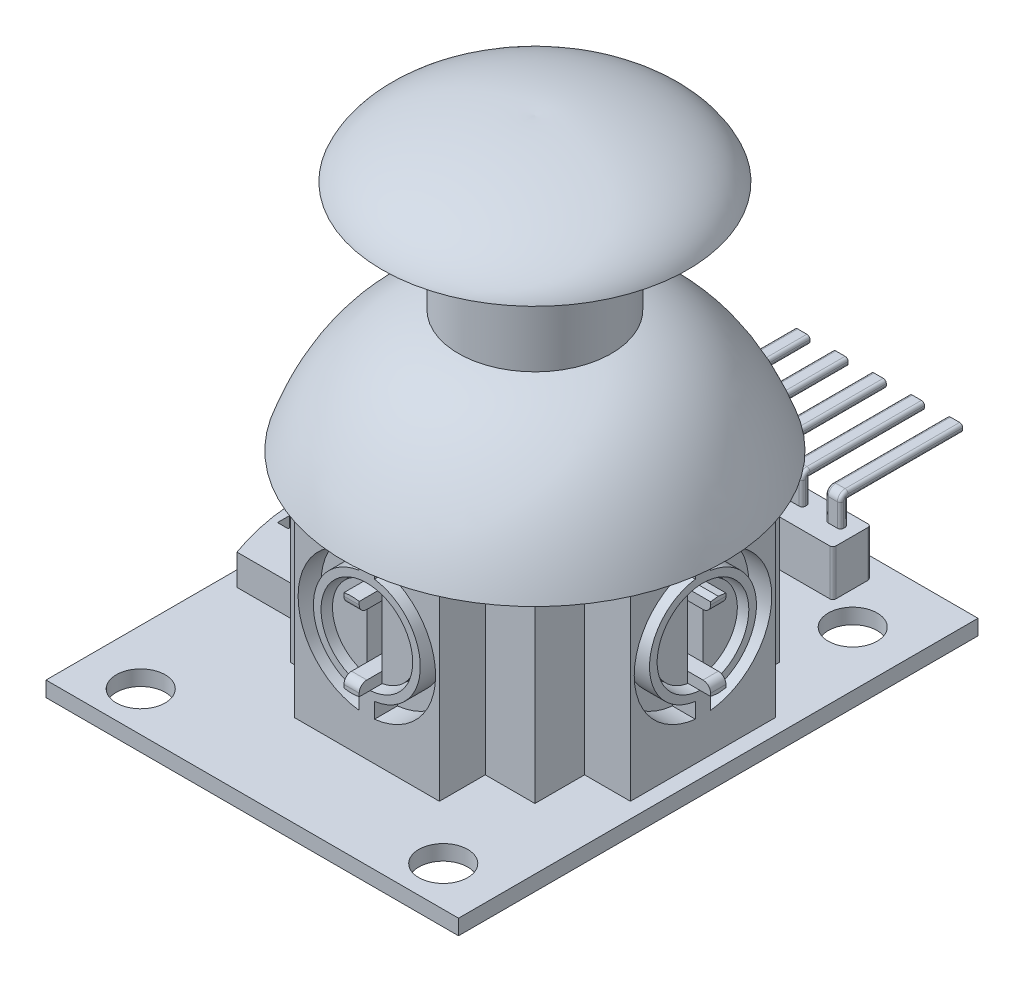
from build123d import *

# Parameters (mm, degrees)
IZIM1_W                           = 27
IZIM1_H                           = 34
IZIM1_R                           = 1.6
Y_KSEKLIK_EKSTR_ZYON1_DEPTH       = 1
IZIM2_W                           = 16
IZIM2_H                           = 16
IZIM2_W_2                         = 15.6
IZIM2_H_2                         = 15.6
Y_KSEKLIK_EKSTR_ZYON2_DEPTH       = 12
IZIM3_W                           = 9.5
IZIM3_H                           = 12
Y_KSEKLIK_EKSTR_ZYON3_DEPTH       = 3
IZIM4_R                           = 3
KES_EKSTR_ZYON1_DEPTH             = 1.5
IZIM5_R                           = 2.75
Y_KSEKLIK_EKSTR_ZYON4_DEPTH       = 1
Y_KSEKLIK_EKSTR_ZYON5_DEPTH       = 1.5
RADYUS1_R                         = 0.5
IZIM7_W                           = 1
IZIM7_H                           = 4
KES_EKSTR_ZYON2_DEPTH             = 1.5
IZIM8_W                           = 0.7
IZIM8_H                           = 5
Y_KSEKLIK_EKSTR_ZYON6_DEPTH       = 2
IZIM9_W                           = 5.85
IZIM9_H                           = 4.793448
Y_KSEKLIK_EKSTR_ZYON7_DEPTH       = 1
IZIM10_W                          = 5.65
IZIM10_H                          = 4.793448
Y_KSEKLIK_EKSTR_ZYON8_DEPTH       = 0.2
IZIM11_R                          = 0.15
Y_KSEKLIK_EKSTR_ZYON9_DEPTH       = 0.1
IZIM12_R                          = 1.75
Y_KSEKLIK_EKSTR_ZYON10_DEPTH      = 2
KES_EKSTR_ZYON3_DEPTH             = 2
IZIM14_R                          = 1.5
Y_KSEKLIK_EKSTR_ZYON11_DEPTH      = 31
IZIM15_R                          = 1.4
Y_KSEKLIK_EKSTR_ZYON12_DEPTH      = 8
IZIM17_R                          = 2.15
Y_KSEKLIK_EKSTR_ZYON14_DEPTH      = 2
Y_KSEKLIK_EKSTR_ZYON15_DEPTH      = 1
IZIM22_W                          = 9.5
IZIM22_H                          = 12
Y_KSEKLIK_EKSTR_ZYON16_DEPTH      = 3
KES_EKSTR_ZYON4_DEPTH             = 1.5
IZIM24_R                          = 3
KES_EKSTR_ZYON5_DEPTH             = 1.5
IZIM25_R                          = 2.75
Y_KSEKLIK_EKSTR_ZYON17_DEPTH      = 1
Y_KSEKLIK_EKSTR_ZYON18_DEPTH      = 1.5
RADYUS2_R                         = 0.5
IZIM27_W                          = 1
IZIM27_H                          = 4
KES_EKSTR_ZYON6_DEPTH             = 1.5
Y_KSEKLIK_EKSTR_ZYON19_DEPTH      = 1
Y_KSEKLIK_EKSTR_ZYON20_DEPTH      = 3
Y_KSEKLIK_EKSTR_ZYON21_DEPTH      = 0.5
Y_KSEKLIK_EKSTR_ZYON21_DEPTH_BACK = 0.5
Y_KSEKLIK_EKSTR_ZYON22_DEPTH      = 0.5
Y_KSEKLIK_EKSTR_ZYON22_DEPTH_BACK = 0.5
Y_KSEKLIK_EKSTR_ZYON23_DEPTH      = 0.5
Y_KSEKLIK_EKSTR_ZYON23_DEPTH_BACK = 0.5
Y_KSEKLIK_EKSTR_ZYON24_DEPTH      = 0.5
Y_KSEKLIK_EKSTR_ZYON24_DEPTH_BACK = 0.5
Y_KSEKLIK_EKSTR_ZYON25_DEPTH      = 0.5
Y_KSEKLIK_EKSTR_ZYON25_DEPTH_BACK = 0.5
RADYUS3_R                         = 0.2


with BuildPart() as part:
    # Çizim1 → Yükseklik-Ekstrüzyon1 (new body)
    with BuildSketch(Plane(origin=(0, 0, 0), x_dir=(1, 0, 0), z_dir=(0, 1, 0))):
        Rectangle(IZIM1_W, IZIM1_H)
        with Locations(Location((-9.9, -14.4, 0), (0, 0, 270))):
            Circle(IZIM1_R, mode=Mode.SUBTRACT)
        with Locations(Location((9.9, -14.4, 0), (0, 0, 90))):
            Circle(IZIM1_R, mode=Mode.SUBTRACT)
        with Locations(Location((-9.9, 12.4, 0), (0, 0, 270))):
            Circle(IZIM1_R, mode=Mode.SUBTRACT)
        with Locations(Location((9.9, 12.4, 0), (0, 0, 90))):
            Circle(IZIM1_R, mode=Mode.SUBTRACT)
    extrude(amount=Y_KSEKLIK_EKSTR_ZYON1_DEPTH)

    # Çizim2 → Yükseklik-Ekstrüzyon2 (add)
    with BuildSketch(Plane(origin=(0, 1, 0), x_dir=(1, 0, 0), z_dir=(0, 1, 0))):
        with Locations((1.5, 0)):
            Rectangle(IZIM2_W, IZIM2_H)
        with Locations((1.5, 0)):
            Rectangle(IZIM2_W_2, IZIM2_H_2, mode=Mode.SUBTRACT)
    extrude(amount=Y_KSEKLIK_EKSTR_ZYON2_DEPTH)

    # Çizim3 → Yükseklik-Ekstrüzyon3 (add)
    with BuildSketch(Plane.XY.offset(8)):
        with Locations((1.5, 7)):
            Rectangle(IZIM3_W, IZIM3_H)
    extrude(amount=Y_KSEKLIK_EKSTR_ZYON3_DEPTH)

    # Çizim4 → Kes-Ekstrüzyon1 (cut)
    with BuildSketch(Plane.XY.offset(11)):
        with Locations((1.5, 8)):
            Circle(IZIM4_R)
        with BuildLine():
            Line((1, 12.472136), (1, 11.464102))
            ThreePointArc((1, 11.464102), (-2, 8), (1, 4.535898))
            Line((1, 4.535898), (1, 3.527864))
            ThreePointArc((1, 3.527864), (-3, 8), (1, 12.472136))
        make_face()
        with BuildLine():
            Line((2, 12.472136), (2, 11.464102))
            ThreePointArc((2, 11.464102), (5, 8), (2, 4.535898))
            Line((2, 4.535898), (2, 3.527864))
            ThreePointArc((2, 3.527864), (6, 8), (2, 12.472136))
        make_face()
    extrude(amount=-KES_EKSTR_ZYON1_DEPTH, mode=Mode.SUBTRACT)

    # Çizim5 → Yükseklik-Ekstrüzyon4 (add)
    with BuildSketch(Plane.XY.offset(9.5)):
        with Locations((1.5, 8)):
            Circle(IZIM5_R)
    extrude(amount=Y_KSEKLIK_EKSTR_ZYON4_DEPTH)

    # Çizim6 → Yükseklik-Ekstrüzyon5 (add)
    with BuildSketch(Plane.XY.offset(10.5)):
        with BuildLine():
            Line((2, 10.704163), (2, 10))
            Line((2, 10), (1, 10))
            Line((1, 10), (1, 10.704163))
            ThreePointArc((1, 10.704163), (1.5, 10.75), (2, 10.704163))
        make_face()
        with BuildLine():
            Line((1, 6), (2, 6))
            Line((2, 6), (2, 5.295837))
            ThreePointArc((2, 5.295837), (1.5, 5.25), (1, 5.295837))
            Line((1, 5.295837), (1, 6))
        make_face()
    extrude(amount=Y_KSEKLIK_EKSTR_ZYON5_DEPTH)

    # Radyus1
    radyus1_edges = [part.edges().sort_by_distance(p)[0] for p in [
        (1.5, 10, 12),
        (1.5, 6, 12),
    ]]
    fillet(radyus1_edges, radius=RADYUS1_R)

    # Çizim7 → Kes-Ekstrüzyon2 (cut)
    with BuildSketch(Plane.XY.offset(10.5)):
        with Locations((1.5, 8)):
            Rectangle(IZIM7_W, IZIM7_H)
    extrude(amount=-KES_EKSTR_ZYON2_DEPTH, mode=Mode.SUBTRACT)

    # Çizim8 → Yükseklik-Ekstrüzyon6 (add)
    with BuildSketch(Plane(origin=(0, 1, 0), x_dir=(1, 0, 0), z_dir=(0, 1, 0))):
        with BuildLine():
            Line((-12.5, 5.5), (-6.5, 5.5))
            Line((-6.5, 5.5), (-6.5, -5.5))
            Line((-6.5, -5.5), (-12.5, -5.5))
            add(Edge.make_bspline(
                [(-12.5, 5.5), (-14.5, 0), (-12.5, -5.5)],
                knots=[0, 0, 0, 1, 1, 1], degree=2))
        make_face()
        with Locations((-12.5, 0)):
            Rectangle(IZIM8_W, IZIM8_H, mode=Mode.SUBTRACT)
    extrude(amount=Y_KSEKLIK_EKSTR_ZYON6_DEPTH)

    # Çizim9 → Yükseklik-Ekstrüzyon7 (add)
    with BuildSketch(Plane(origin=(0, 3, 0), x_dir=(1, 0, 0), z_dir=(0, 1, 0))):
        with Locations((-9.225, 0)):
            Rectangle(IZIM9_W, IZIM9_H)
    extrude(amount=Y_KSEKLIK_EKSTR_ZYON7_DEPTH)

    # Çizim10 → Yükseklik-Ekstrüzyon8 (add)
    with BuildSketch(Plane(origin=(0, 4, 0), x_dir=(1, 0, 0), z_dir=(0, 1, 0))):
        with Locations((-9.325, 0)):
            Rectangle(IZIM10_W, IZIM10_H)
    extrude(amount=Y_KSEKLIK_EKSTR_ZYON8_DEPTH)

    # Çizim11 → Yükseklik-Ekstrüzyon9 (add)
    with BuildSketch(Plane(origin=(0, 4.2, 0), x_dir=(1, 0, 0), z_dir=(0, 1, 0))):
        with Locations(Location((-11.796392, 2.096724, 0), (0, 0, 270))):
            Circle(IZIM11_R)
        with Locations(Location((-6.853608, 2.096724, 0), (0, 0, 90))):
            Circle(IZIM11_R)
        with Locations(Location((-6.853608, -2.096724, 0), (0, 0, 270))):
            Circle(IZIM11_R)
        with Locations(Location((-11.796392, -2.096724, 0), (0, 0, 90))):
            Circle(IZIM11_R)
    extrude(amount=Y_KSEKLIK_EKSTR_ZYON9_DEPTH)

    # Çizim12 → Yükseklik-Ekstrüzyon10 (add)
    with BuildSketch(Plane(origin=(0, 4.2, 0), x_dir=(1, 0, 0), z_dir=(0, 1, 0))):
        with Locations(Location((-9.325, 0, 0), (0, 0, 270))):
            Circle(IZIM12_R)
    extrude(amount=Y_KSEKLIK_EKSTR_ZYON10_DEPTH)

    # Çizim13 → Kes-Ekstrüzyon3 (cut)
    with BuildSketch(Plane.ZY.offset(6.5)):
        with BuildLine():
            Line((-3.5, 6.2), (-1.926136, 6.2))
            ThreePointArc((-1.926136, 6.2), (0, 11.5), (1.926136, 6.2))
            Line((1.926136, 6.2), (3.5, 6.2))
            ThreePointArc((3.5, 6.2), (3.853553, 6.053553), (4, 5.7))
            Line((4, 5.7), (4, 1))
            Line((4, 1), (-4, 1))
            Line((-4, 1), (-4, 5.7))
            ThreePointArc((-4, 5.7), (-3.853553, 6.053553), (-3.5, 6.2))
        make_face()
    extrude(amount=-KES_EKSTR_ZYON3_DEPTH, mode=Mode.SUBTRACT)

    # Çizim14 → Yükseklik-Ekstrüzyon11 (add)
    with BuildSketch(Plane(origin=(0, 1, 0), x_dir=(1, 0, 0), z_dir=(0, 1, 0))):
        with Locations(Location((1.5, 0, 0), (0, 0, 270))):
            Circle(IZIM14_R)
    extrude(amount=Y_KSEKLIK_EKSTR_ZYON11_DEPTH)

    # Çizim15 → Yükseklik-Ekstrüzyon12 (add)
    with BuildSketch(Plane(origin=(1.5, 0, 0), x_dir=(0, 0, -1), z_dir=(1, 0, 0))):
        with Locations((0, 8.5)):
            Circle(IZIM15_R)
    extrude(amount=-Y_KSEKLIK_EKSTR_ZYON12_DEPTH)

    # Çizim17 → Yükseklik-Ekstrüzyon14 (add)
    with BuildSketch(Plane.ZY.offset(6.5)):
        with Locations((0, 8.5)):
            Circle(IZIM17_R)
    extrude(amount=Y_KSEKLIK_EKSTR_ZYON14_DEPTH)

    # Çizim18 → Yükseklik-Ekstrüzyon15 (add)
    with BuildSketch(Plane.ZY.offset(8.5)):
        with BuildLine():
            Line((1, 8.5), (1, 10.6))
            ThreePointArc((1, 10.6), (0.941421, 10.741421), (0.8, 10.8))
            Line((0.8, 10.8), (-0.8, 10.8))
            ThreePointArc((-0.8, 10.8), (-0.941421, 10.741421), (-1, 10.6))
            Line((-1, 10.6), (-1, 8.5))
            ThreePointArc((-1, 8.5), (0, 7.5), (1, 8.5))
        make_face()
    extrude(amount=Y_KSEKLIK_EKSTR_ZYON15_DEPTH)



with BuildPart() as body_2:
    # Çizim19 → Döndür1 (revolve)
    with BuildSketch(Plane(origin=(1.5, 0, 0), x_dir=(0, 0, -1), z_dir=(1, 0, 0)), mode=Mode.PRIVATE) as d_nd_r1_sk:
        with BuildLine():
            Line((-12.5, 13), (-12.288133, 13))
            add(Edge.make_bspline(
                [(-12.288133, 13), (-12.111507, 13.502279), (-11.702122, 14.536697), (-11.015704, 15.891074), (-10.226286, 17.116712), (-9.058841, 18.530653), (-7.713634, 19.626363), (-6.197298, 20.40463), (-5.366566, 20.692463), (-4.947265, 20.807078)],
                knots=[0.004762, 0.004762, 0.004762, 0.004762, 0.113958, 0.227916, 0.341874, 0.455832, 0.683748, 0.797706, 0.911664, 0.911664, 0.911664, 0.911664], degree=3))
            Line((-4.947265, 20.807078), (-4.8, 20.807078))
            Line((-4.8, 20.807078), (-4.8, 21))
            Line((-4.8, 21), (-4.8, 28.250085))
            Line((-4.8, 28.250085), (-5, 28.250085))
            Line((-5, 28.250085), (-5, 21))
            add(Edge.make_bspline(
                [(-12.5, 13), (-10.213592, 19.574874), (-5, 21)],
                knots=[0, 0, 0, 0.911664, 0.911664, 0.911664], degree=2))
        make_face()
    revolve(d_nd_r1_sk.sketch.rotate(Axis((1.5, 13, 0), (0, 1, 0)), 180), axis=Axis((1.5, 13, 0), (0, 1, 0)))


with BuildPart() as part_1:
    add(part.part)

    add(body_2.part)  # Döndür3 merges body 2
    # Çizim21 → Döndür3 (revolve)
    with BuildSketch(Plane(origin=(1.5, 0, 0), x_dir=(0, 0, -1), z_dir=(1, 0, 0)), mode=Mode.PRIVATE) as d_nd_r3_sk:
        with BuildLine():
            Line((0, 32), (0, 31.800503))
            Line((0, 31.800503), (-0.014182, 31.800503))
            add(Edge.make_bspline(
                [(-0.014182, 31.800503), (-0.21638, 31.814878), (-0.610932, 31.829554), (-1.487447, 31.813408), (-2.658294, 31.705464), (-4.127855, 31.444872), (-5.581424, 31.059598), (-6.945351, 30.557646), (-8.144428, 29.947028), (-8.941287, 29.360532), (-9.424448, 28.847791), (-9.603184, 28.590125), (-9.682203, 28.450085)],
                knots=[0, 0, 0, 0, 0.047842, 0.095684, 0.191367, 0.287051, 0.382735, 0.478418, 0.574102, 0.669786, 0.717628, 0.765469, 0.765469, 0.765469, 0.765469], degree=3))
            Line((-9.682203, 28.450085), (-4.40609, 28.450085))
            Line((-4.40609, 28.450085), (-4.40609, 28.250085))
            Line((-4.40609, 28.250085), (-10, 28.250085))
            add(Edge.make_bspline(
                [(0, 32), (-0.745802, 32.053019), (-4.590452, 31.898517), (-9.220348, 30.199043), (-10, 28.250085)],
                knots=[0, 0, 0, 0, 0.179556, 0.797541, 0.797541, 0.797541, 0.797541], degree=3))
        make_face()
    revolve(d_nd_r3_sk.sketch.rotate(Axis((1.5, 28.250085, 0), (0, 1, 0)), 180), axis=Axis((1.5, 28.250085, 0), (0, 1, 0)))

    # Çizim22 → Yükseklik-Ekstrüzyon16 (add)
    with BuildSketch(Plane(origin=(9.5, 0, 0), x_dir=(0, 0, -1), z_dir=(1, 0, 0))):
        with Locations((0, 7)):
            Rectangle(IZIM22_W, IZIM22_H)
    extrude(amount=Y_KSEKLIK_EKSTR_ZYON16_DEPTH)

    # Çizim23 → Kes-Ekstrüzyon4 (cut)
    with BuildSketch(Plane(origin=(12.5, 0, 0), x_dir=(0, 0, -1), z_dir=(1, 0, 0))):
        with BuildLine():
            Line((-0.5, 12.472136), (-0.5, 11.464102))
            ThreePointArc((-0.5, 11.464102), (-3.5, 8), (-0.5, 4.535898))
            Line((-0.5, 4.535898), (-0.5, 3.527864))
            ThreePointArc((-0.5, 3.527864), (-4.5, 8), (-0.5, 12.472136))
        make_face()
        with BuildLine():
            Line((0.5, 12.472136), (0.5, 11.464102))
            ThreePointArc((0.5, 11.464102), (3.5, 8), (0.5, 4.535898))
            Line((0.5, 4.535898), (0.5, 3.527864))
            ThreePointArc((0.5, 3.527864), (4.5, 8), (0.5, 12.472136))
        make_face()
    extrude(amount=-KES_EKSTR_ZYON4_DEPTH, mode=Mode.SUBTRACT)

    # Çizim24 → Kes-Ekstrüzyon5 (cut)
    with BuildSketch(Plane(origin=(12.5, 0, 0), x_dir=(0, 0, -1), z_dir=(1, 0, 0))):
        with Locations((0, 8)):
            Circle(IZIM24_R)
    extrude(amount=-KES_EKSTR_ZYON5_DEPTH, mode=Mode.SUBTRACT)

    # Çizim25 → Yükseklik-Ekstrüzyon17 (add)
    with BuildSketch(Plane(origin=(11, 0, 0), x_dir=(0, 0, -1), z_dir=(1, 0, 0))):
        with Locations((0, 8)):
            Circle(IZIM25_R)
    extrude(amount=Y_KSEKLIK_EKSTR_ZYON17_DEPTH)

    # Çizim26 → Yükseklik-Ekstrüzyon18 (add)
    with BuildSketch(Plane(origin=(12, 0, 0), x_dir=(0, 0, -1), z_dir=(1, 0, 0))):
        Polygon((0.5, 10), (-0.5, 10), (-0.5, 10.683557), (0, 10.75), (0.5, 10.683557), align=None)
        Polygon((0.5, 6), (0.5, 5.316705), (0, 5.25), (-0.5, 5.316705), (-0.5, 6), align=None)
    extrude(amount=Y_KSEKLIK_EKSTR_ZYON18_DEPTH)

    # Radyus2
    radyus2_edges = [part_1.edges().sort_by_distance(p)[0] for p in [
        (13.5, 10, 0),
        (13.5, 6, 0),
    ]]
    fillet(radyus2_edges, radius=RADYUS2_R)

    # Çizim27 → Kes-Ekstrüzyon6 (cut)
    with BuildSketch(Plane(origin=(12, 0, 0), x_dir=(0, 0, -1), z_dir=(1, 0, 0))):
        with Locations((0, 8)):
            Rectangle(IZIM27_W, IZIM27_H)
    extrude(amount=-KES_EKSTR_ZYON6_DEPTH, mode=Mode.SUBTRACT)

    # Çizim28 → Yükseklik-Ekstrüzyon19 (add)
    with BuildSketch(Plane(origin=(0, 0, -8), x_dir=(-1, 0, 0), z_dir=(0, 0, -1))):
        Polygon((-5, 8), (-3.5, 8), (-3.5, 7), (0.5, 7), (0.5, 8), (2, 8), (2.5, 7.5), (2.5, 1), (-5.5, 1), (-5.5, 7.5), align=None)
    extrude(amount=Y_KSEKLIK_EKSTR_ZYON19_DEPTH)

    # Çizim29 → Yükseklik-Ekstrüzyon20 (add)
    with BuildSketch(Plane(origin=(0, 1, 0), x_dir=(1, 0, 0), z_dir=(0, 1, 0))):
        with BuildLine():
            Line((-4.55, 15.75), (7.55, 15.75))
            ThreePointArc((7.55, 15.75), (7.691421, 15.691421), (7.75, 15.55))
            Line((7.75, 15.55), (7.75, 13.45))
            ThreePointArc((7.75, 13.45), (7.691421, 13.308579), (7.55, 13.25))
            Line((7.55, 13.25), (-4.55, 13.25))
            ThreePointArc((-4.55, 13.25), (-4.691421, 13.308579), (-4.75, 13.45))
            Line((-4.75, 13.45), (-4.75, 15.55))
            ThreePointArc((-4.75, 15.55), (-4.691421, 15.691421), (-4.55, 15.75))
        make_face()
    extrude(amount=Y_KSEKLIK_EKSTR_ZYON20_DEPTH)

    # Çizim30 → Yükseklik-Ekstrüzyon21 (add, two sides)
    with BuildSketch(Plane(origin=(1.5, 0, 0), x_dir=(0, 0, -1), z_dir=(1, 0, 0))) as y_kseklik_ekstr_zyon21_sk:
        with BuildLine():
            Line((14.5, 4), (14.5, 5.5))
            ThreePointArc((14.5, 5.5), (14.646447, 5.853553), (15, 6))
            Line((15, 6), (22.5, 6))
            Line((22.5, 6), (22.5, 5.5))
            Line((22.5, 5.5), (15, 5.5))
            Line((15, 5.5), (15, 4))
            Line((15, 4), (14.5, 4))
        make_face()
    extrude(amount=Y_KSEKLIK_EKSTR_ZYON21_DEPTH)
    extrude(y_kseklik_ekstr_zyon21_sk.sketch, amount=-Y_KSEKLIK_EKSTR_ZYON21_DEPTH_BACK)

    # Çizim31 → Yükseklik-Ekstrüzyon22 (add, two sides)
    with BuildSketch(Plane(origin=(4, 0, 0), x_dir=(0, 0, -1), z_dir=(1, 0, 0))) as y_kseklik_ekstr_zyon22_sk:
        with BuildLine():
            Line((14.5, 4), (14.5, 5.5))
            ThreePointArc((14.5, 5.5), (14.646447, 5.853553), (15, 6))
            Line((15, 6), (22.5, 6))
            Line((22.5, 6), (22.5, 5.5))
            Line((22.5, 5.5), (15, 5.5))
            Line((15, 5.5), (15, 4))
            Line((15, 4), (14.5, 4))
        make_face()
    extrude(amount=Y_KSEKLIK_EKSTR_ZYON22_DEPTH)
    extrude(y_kseklik_ekstr_zyon22_sk.sketch, amount=-Y_KSEKLIK_EKSTR_ZYON22_DEPTH_BACK)

    # Çizim33 → Yükseklik-Ekstrüzyon23 (add, two sides)
    with BuildSketch(Plane(origin=(6.5, 0, 0), x_dir=(0, 0, -1), z_dir=(1, 0, 0))) as y_kseklik_ekstr_zyon23_sk:
        with BuildLine():
            Line((14.5, 4), (14.5, 5.5))
            ThreePointArc((14.5, 5.5), (14.646447, 5.853553), (15, 6))
            Line((15, 6), (22.5, 6))
            Line((22.5, 6), (22.5, 5.5))
            Line((22.5, 5.5), (15, 5.5))
            Line((15, 5.5), (15, 4))
            Line((15, 4), (14.5, 4))
        make_face()
    extrude(amount=Y_KSEKLIK_EKSTR_ZYON23_DEPTH)
    extrude(y_kseklik_ekstr_zyon23_sk.sketch, amount=-Y_KSEKLIK_EKSTR_ZYON23_DEPTH_BACK)

    # Çizim34 → Yükseklik-Ekstrüzyon24 (add, two sides)
    with BuildSketch(Plane(origin=(-1, 0, 0), x_dir=(0, 0, -1), z_dir=(1, 0, 0))) as y_kseklik_ekstr_zyon24_sk:
        with BuildLine():
            Line((14.5, 4), (14.5, 5.5))
            ThreePointArc((14.5, 5.5), (14.646447, 5.853553), (15, 6))
            Line((15, 6), (22.5, 6))
            Line((22.5, 6), (22.5, 5.5))
            Line((22.5, 5.5), (15, 5.5))
            Line((15, 5.5), (15, 4))
            Line((15, 4), (14.5, 4))
        make_face()
    extrude(amount=Y_KSEKLIK_EKSTR_ZYON24_DEPTH)
    extrude(y_kseklik_ekstr_zyon24_sk.sketch, amount=-Y_KSEKLIK_EKSTR_ZYON24_DEPTH_BACK)

    # Çizim35 → Yükseklik-Ekstrüzyon25 (add, two sides)
    with BuildSketch(Plane(origin=(-3.5, 0, 0), x_dir=(0, 0, -1), z_dir=(1, 0, 0))) as y_kseklik_ekstr_zyon25_sk:
        with BuildLine():
            Line((14.5, 4), (14.5, 5.5))
            ThreePointArc((14.5, 5.5), (14.646447, 5.853553), (15, 6))
            Line((15, 6), (22.5, 6))
            Line((22.5, 6), (22.5, 5.5))
            Line((22.5, 5.5), (15, 5.5))
            Line((15, 5.5), (15, 4))
            Line((15, 4), (14.5, 4))
        make_face()
    extrude(amount=Y_KSEKLIK_EKSTR_ZYON25_DEPTH)
    extrude(y_kseklik_ekstr_zyon25_sk.sketch, amount=-Y_KSEKLIK_EKSTR_ZYON25_DEPTH_BACK)

    # Radyus3
    radyus3_edges = [part_1.edges().sort_by_distance(p)[0] for p in [
        (1, 4.75, -14.5),
        (1, 5.853553, -14.646447),
        (1, 6, -18.75),
        (1, 5.5, -18.75),
        (1, 4.75, -15),
        (2, 4.75, -15),
        (2, 5.5, -18.75),
        (2, 6, -18.75),
        (2, 5.853553, -14.646447),
        (2, 4.75, -14.5),
        (3.5, 4.75, -14.5),
        (3.5, 5.853553, -14.646447),
        (3.5, 6, -18.75),
        (3.5, 5.5, -18.75),
        (3.5, 4.75, -15),
        (4.5, 4.75, -15),
        (4.5, 5.5, -18.75),
        (4.5, 6, -18.75),
        (4.5, 5.853553, -14.646447),
        (4.5, 4.75, -14.5),
        (6, 4.75, -14.5),
        (6, 5.853553, -14.646447),
        (6, 6, -18.75),
        (6, 5.5, -18.75),
        (6, 4.75, -15),
        (7, 4.75, -15),
        (7, 5.5, -18.75),
        (7, 6, -18.75),
        (7, 5.853553, -14.646447),
        (7, 4.75, -14.5),
        (-1.5, 4.75, -14.5),
        (-1.5, 5.853553, -14.646447),
        (-1.5, 6, -18.75),
        (-1.5, 5.5, -18.75),
        (-1.5, 4.75, -15),
        (-0.5, 4.75, -15),
        (-0.5, 5.5, -18.75),
        (-0.5, 6, -18.75),
        (-0.5, 5.853553, -14.646447),
        (-0.5, 4.75, -14.5),
        (-4, 4.75, -14.5),
        (-4, 5.853553, -14.646447),
        (-4, 6, -18.75),
        (-4, 5.5, -18.75),
        (-4, 4.75, -15),
        (-3, 4.75, -15),
        (-3, 5.5, -18.75),
        (-3, 6, -18.75),
        (-3, 5.853553, -14.646447),
        (-3, 4.75, -14.5),
    ]]
    fillet(radyus3_edges, radius=RADYUS3_R)


solid = part_1.part
